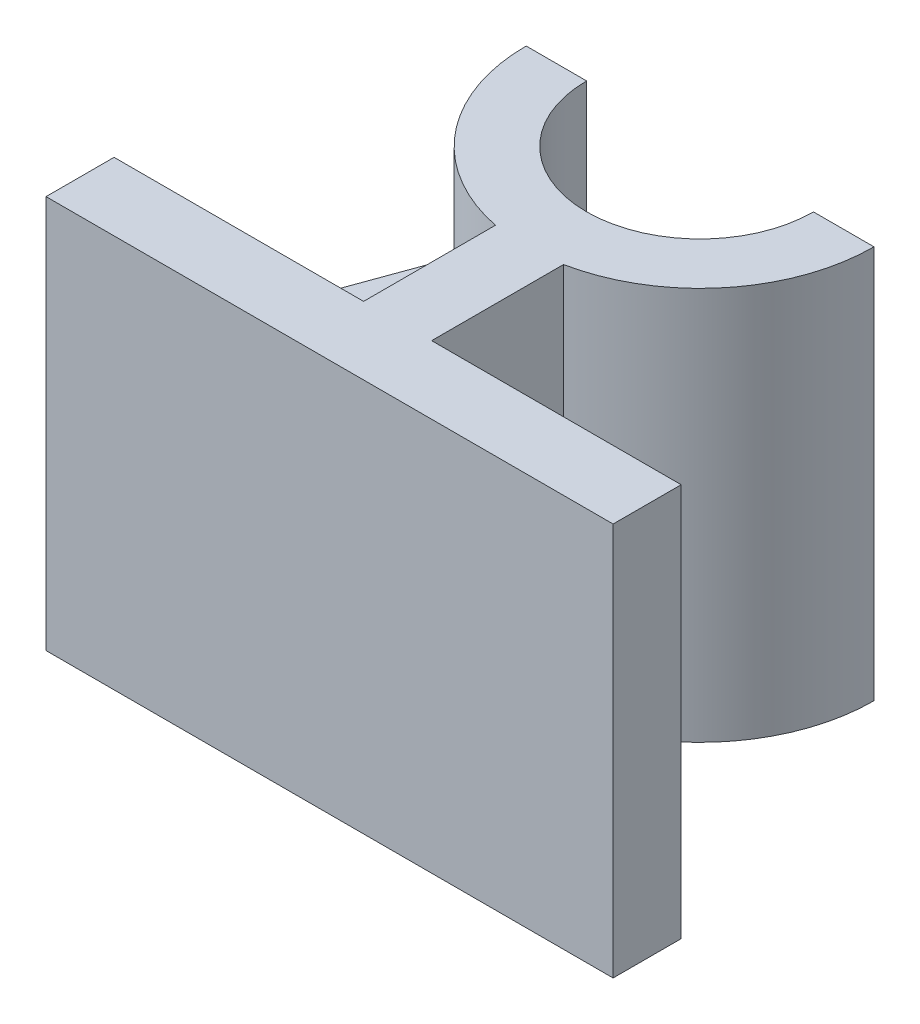
from build123d import *

# Parameters (mm, degrees)
SKETCH8_W           = 75
SKETCH8_H           = 9
BOSS_EXTRUDE5_DEPTH = 52
BOSS_EXTRUDE6_DEPTH = 8


with BuildPart() as part:
    # Sketch8 → Boss-Extrude5 (new body)
    with BuildSketch(Plane(origin=(0, 0, 0), x_dir=(1, 0, 0), z_dir=(0, 1, 0))):
        with BuildLine():
            Line((-4.5, 21.5), (-4.5, 4.5))
            Line((-4.5, 4.5), (4.5, 4.5))
            Line((4.5, 4.5), (4.5, 21.5))
            Line((4.5, 21.5), (4.5, 21.944512863))
            ThreePointArc((4.5, 21.944512863), (17.783419244, 29.914047854), (23, 44.5))
            Line((23, 44.5), (15, 44.5))
            ThreePointArc((15, 44.5), (0, 29.5), (-15, 44.5))
            Line((-15, 44.5), (-23, 44.5))
            ThreePointArc((-23, 44.5), (-17.783419244, 29.914047854), (-4.5, 21.944512863))
            Line((-4.5, 21.944512863), (-4.5, 21.5))
        make_face()
        Rectangle(SKETCH8_W, SKETCH8_H)
    extrude(amount=-BOSS_EXTRUDE5_DEPTH)

    # Sketch9 → Boss-Extrude6 (add)
    with BuildSketch(Plane(origin=(0, -30, 0), x_dir=(-1, 0, 0), z_dir=(0, -1, 0))):
        with BuildLine():
            Line((23, 44.5), (37.5, 4.5))
            Line((37.5, 4.5), (4.5, 4.5))
            Line((4.5, 4.5), (4.5, 21.944512863))
            ThreePointArc((4.5, 21.944512863), (17.783419244, 29.914047854), (23, 44.5))
        make_face()
    extrude(amount=-BOSS_EXTRUDE6_DEPTH)


solid = part.part
